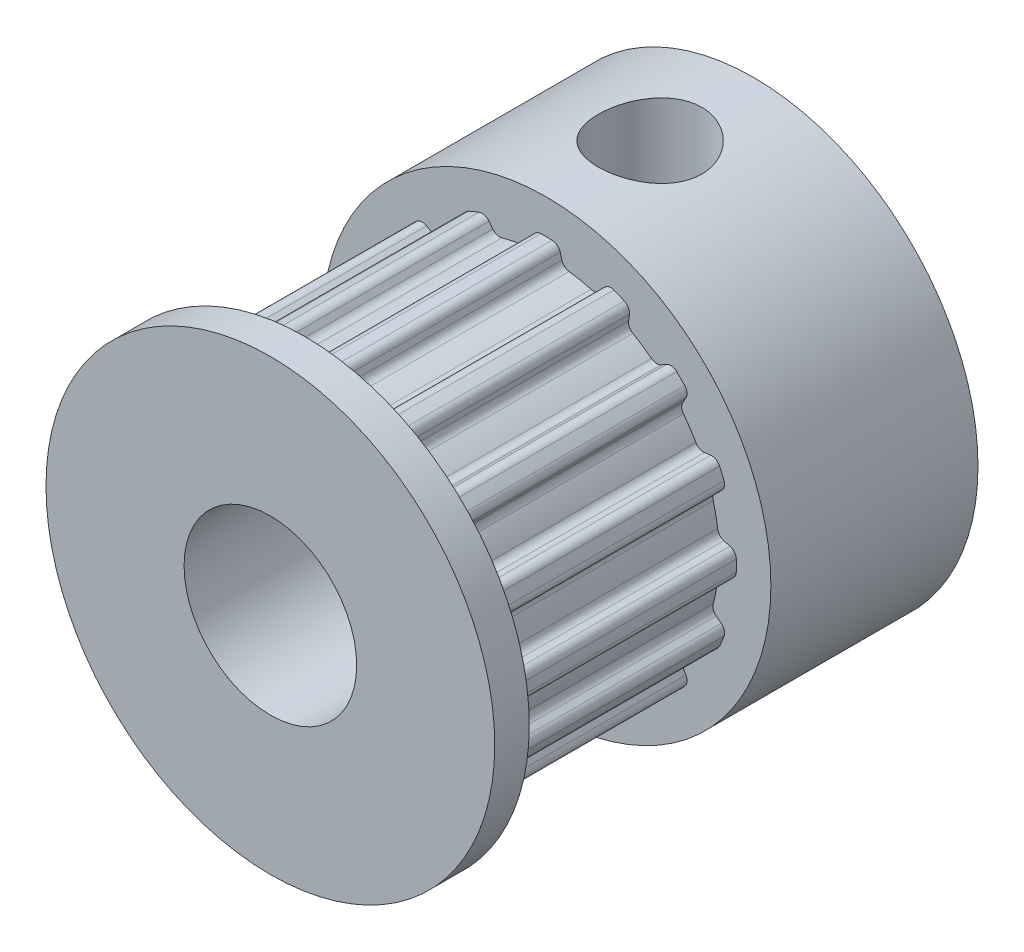
from build123d import *

# Parameters (mm, degrees)
SKETCH1_R           = 6.5
SKETCH1_R_2         = 2.5
BOSS_EXTRUDE1_DEPTH = 6
SKETCH2_R           = 2.5
BOSS_EXTRUDE2_DEPTH = 7
SKETCH3_R           = 6.5
SKETCH3_R_2         = 2.5
BOSS_EXTRUDE3_DEPTH = 1
SKETCH4_R           = 1.5
CUT_EXTRUDE1_DEPTH  = 7.5
SKETCH5_R           = 1.5
CUT_EXTRUDE2_DEPTH  = 7.5000001


with BuildPart() as part:
    # Sketch1 → Boss-Extrude1 (new body)
    with BuildSketch(Plane.XY):
        Circle(SKETCH1_R)
        Circle(SKETCH1_R_2, mode=Mode.SUBTRACT)
    extrude(amount=BOSS_EXTRUDE1_DEPTH)

    # Sketch2 → Boss-Extrude2 (add)
    with BuildSketch(Plane.XY.offset(6)):
        with BuildLine():
            Line((0.445491151, 5.138938457), (0.397701665, 5.313631767))
            ThreePointArc((0.397701665, 5.313631767), (0.311179854, 5.444116778), (0.164017219, 5.497553852))
            ThreePointArc((0.164017219, 5.497553852), (0, 5.5), (-0.164017219, 5.497553852))
            ThreePointArc((-0.164017219, 5.497553852), (-0.311179854, 5.444116778), (-0.397701665, 5.313631767))
            Line((-0.397701665, 5.313631767), (-0.445491151, 5.138938457))
            ThreePointArc((-0.445491151, 5.138938457), (-0.522261752, 5.016536464), (-0.653934215, 4.957052556))
            ThreePointArc((-0.653934215, 4.957052556), (-0.97545161, 4.903926402), (-1.292825449, 4.829969188))
            ThreePointArc((-1.292825449, 4.829969188), (-1.437238449, 4.834536283), (-1.555006451, 4.918242142))
            Line((-1.555006451, 4.918242142), (-1.666010414, 5.061349471))
            ThreePointArc((-1.666010414, 5.061349471), (-1.795880597, 5.148791439), (-1.952290626, 5.141844155))
            ThreePointArc((-1.952290626, 5.141844155), (-2.104758878, 5.081337429), (-2.255354929, 5.01631081))
            ThreePointArc((-2.255354929, 5.01631081), (-2.370865993, 4.91062469), (-2.400867272, 4.756961795))
            Line((-2.400867272, 4.756961795), (-2.378166764, 4.577277976))
            ThreePointArc((-2.378166764, 4.577277976), (-2.402252336, 4.434814443), (-2.501138324, 4.329469608))
            ThreePointArc((-2.501138324, 4.329469608), (-2.777851165, 4.157348062), (-3.042764159, 3.967566795))
            ThreePointArc((-3.042764159, 3.967566795), (-3.177932125, 3.916521778), (-3.318768417, 3.948788045))
            Line((-3.318768417, 3.948788045), (-3.476087511, 4.0385226))
            ThreePointArc((-3.476087511, 4.0385226), (-3.629534507, 4.069609276), (-3.771379921, 4.003335296))
            ThreePointArc((-3.771379921, 4.003335296), (-3.889087297, 3.889087297), (-4.003335296, 3.771379921))
            ThreePointArc((-4.003335296, 3.771379921), (-4.069609276, 3.629534507), (-4.0385226, 3.476087511))
            Line((-4.0385226, 3.476087511), (-3.948788045, 3.318768417))
            ThreePointArc((-3.948788045, 3.318768417), (-3.916521778, 3.177932125), (-3.967566795, 3.042764159))
            ThreePointArc((-3.967566795, 3.042764159), (-4.157348062, 2.777851165), (-4.329469608, 2.501138324))
            ThreePointArc((-4.329469608, 2.501138324), (-4.434814443, 2.402252336), (-4.577277976, 2.378166764))
            Line((-4.577277976, 2.378166764), (-4.756961795, 2.400867272))
            ThreePointArc((-4.756961795, 2.400867272), (-4.91062469, 2.370865993), (-5.01631081, 2.255354929))
            ThreePointArc((-5.01631081, 2.255354929), (-5.081337429, 2.104758878), (-5.141844155, 1.952290626))
            ThreePointArc((-5.141844155, 1.952290626), (-5.148791439, 1.795880597), (-5.061349471, 1.666010414))
            Line((-5.061349471, 1.666010414), (-4.918242142, 1.555006451))
            ThreePointArc((-4.918242142, 1.555006451), (-4.834536283, 1.437238449), (-4.829969188, 1.292825449))
            ThreePointArc((-4.829969188, 1.292825449), (-4.903926402, 0.97545161), (-4.957052556, 0.653934215))
            ThreePointArc((-4.957052556, 0.653934215), (-5.016536464, 0.522261752), (-5.138938457, 0.445491151))
            Line((-5.138938457, 0.445491151), (-5.313631767, 0.397701665))
            ThreePointArc((-5.313631767, 0.397701665), (-5.444116778, 0.311179854), (-5.497553852, 0.164017219))
            ThreePointArc((-5.497553852, 0.164017219), (-5.5, 0), (-5.497553852, -0.164017219))
            ThreePointArc((-5.497553852, -0.164017219), (-5.444116778, -0.311179854), (-5.313631767, -0.397701665))
            Line((-5.313631767, -0.397701665), (-5.138938457, -0.445491151))
            ThreePointArc((-5.138938457, -0.445491151), (-5.016536464, -0.522261752), (-4.957052556, -0.653934215))
            ThreePointArc((-4.957052556, -0.653934215), (-4.903926402, -0.97545161), (-4.829969188, -1.292825449))
            ThreePointArc((-4.829969188, -1.292825449), (-4.834536283, -1.437238449), (-4.918242142, -1.555006451))
            Line((-4.918242142, -1.555006451), (-5.061349471, -1.666010414))
            ThreePointArc((-5.061349471, -1.666010414), (-5.148791439, -1.795880597), (-5.141844155, -1.952290626))
            ThreePointArc((-5.141844155, -1.952290626), (-5.081337429, -2.104758878), (-5.01631081, -2.255354929))
            ThreePointArc((-5.01631081, -2.255354929), (-4.91062469, -2.370865993), (-4.756961795, -2.400867272))
            Line((-4.756961795, -2.400867272), (-4.577277976, -2.378166764))
            ThreePointArc((-4.577277976, -2.378166764), (-4.434814443, -2.402252336), (-4.329469608, -2.501138324))
            ThreePointArc((-4.329469608, -2.501138324), (-4.157348062, -2.777851165), (-3.967566795, -3.042764159))
            ThreePointArc((-3.967566795, -3.042764159), (-3.916521778, -3.177932125), (-3.948788045, -3.318768417))
            Line((-3.948788045, -3.318768417), (-4.0385226, -3.476087511))
            ThreePointArc((-4.0385226, -3.476087511), (-4.069609276, -3.629534507), (-4.003335296, -3.771379921))
            ThreePointArc((-4.003335296, -3.771379921), (-3.889087297, -3.889087297), (-3.771379921, -4.003335296))
            ThreePointArc((-3.771379921, -4.003335296), (-3.629534507, -4.069609276), (-3.476087511, -4.0385226))
            Line((-3.476087511, -4.0385226), (-3.318768417, -3.948788045))
            ThreePointArc((-3.318768417, -3.948788045), (-3.177932125, -3.916521778), (-3.042764159, -3.967566795))
            ThreePointArc((-3.042764159, -3.967566795), (-2.777851165, -4.157348062), (-2.501138324, -4.329469608))
            ThreePointArc((-2.501138324, -4.329469608), (-2.402252336, -4.434814443), (-2.378166764, -4.577277976))
            Line((-2.378166764, -4.577277976), (-2.400867272, -4.756961795))
            ThreePointArc((-2.400867272, -4.756961795), (-2.370865993, -4.91062469), (-2.255354929, -5.01631081))
            ThreePointArc((-2.255354929, -5.01631081), (-2.104758878, -5.081337429), (-1.952290626, -5.141844155))
            ThreePointArc((-1.952290626, -5.141844155), (-1.795880597, -5.148791439), (-1.666010414, -5.061349471))
            Line((-1.666010414, -5.061349471), (-1.555006451, -4.918242142))
            ThreePointArc((-1.555006451, -4.918242142), (-1.437238449, -4.834536283), (-1.292825449, -4.829969188))
            ThreePointArc((-1.292825449, -4.829969188), (-0.97545161, -4.903926402), (-0.653934215, -4.957052556))
            ThreePointArc((-0.653934215, -4.957052556), (-0.522261752, -5.016536464), (-0.445491151, -5.138938457))
            Line((-0.445491151, -5.138938457), (-0.397701665, -5.313631767))
            ThreePointArc((-0.397701665, -5.313631767), (-0.311179854, -5.444116778), (-0.164017219, -5.497553852))
            ThreePointArc((-0.164017219, -5.497553852), (0, -5.5), (0.164017219, -5.497553852))
            ThreePointArc((0.164017219, -5.497553852), (0.311179854, -5.444116778), (0.397701665, -5.313631767))
            Line((0.397701665, -5.313631767), (0.445491151, -5.138938457))
            ThreePointArc((0.445491151, -5.138938457), (0.522261752, -5.016536464), (0.653934215, -4.957052556))
            ThreePointArc((0.653934215, -4.957052556), (0.97545161, -4.903926402), (1.292825449, -4.829969188))
            ThreePointArc((1.292825449, -4.829969188), (1.437238449, -4.834536283), (1.555006451, -4.918242142))
            Line((1.555006451, -4.918242142), (1.666010414, -5.061349471))
            ThreePointArc((1.666010414, -5.061349471), (1.795880597, -5.148791439), (1.952290626, -5.141844155))
            ThreePointArc((1.952290626, -5.141844155), (2.104758878, -5.081337429), (2.255354929, -5.01631081))
            ThreePointArc((2.255354929, -5.01631081), (2.370865993, -4.91062469), (2.400867272, -4.756961795))
            Line((2.400867272, -4.756961795), (2.378166764, -4.577277976))
            ThreePointArc((2.378166764, -4.577277976), (2.402252336, -4.434814443), (2.501138324, -4.329469608))
            ThreePointArc((2.501138324, -4.329469608), (2.777851165, -4.157348062), (3.042764159, -3.967566795))
            ThreePointArc((3.042764159, -3.967566795), (3.177932125, -3.916521778), (3.318768417, -3.948788045))
            Line((3.318768417, -3.948788045), (3.476087511, -4.0385226))
            ThreePointArc((3.476087511, -4.0385226), (3.629534507, -4.069609276), (3.771379921, -4.003335296))
            ThreePointArc((3.771379921, -4.003335296), (3.889087297, -3.889087297), (4.003335296, -3.771379921))
            ThreePointArc((4.003335296, -3.771379921), (4.069609276, -3.629534507), (4.0385226, -3.476087511))
            Line((4.0385226, -3.476087511), (3.948788045, -3.318768417))
            ThreePointArc((3.948788045, -3.318768417), (3.916521778, -3.177932125), (3.967566795, -3.042764159))
            ThreePointArc((3.967566795, -3.042764159), (4.157348062, -2.777851165), (4.329469608, -2.501138324))
            ThreePointArc((4.329469608, -2.501138324), (4.434814443, -2.402252336), (4.577277976, -2.378166764))
            Line((4.577277976, -2.378166764), (4.756961795, -2.400867272))
            ThreePointArc((4.756961795, -2.400867272), (4.91062469, -2.370865993), (5.01631081, -2.255354929))
            ThreePointArc((5.01631081, -2.255354929), (5.081337429, -2.104758878), (5.141844155, -1.952290626))
            ThreePointArc((5.141844155, -1.952290626), (5.148791439, -1.795880597), (5.061349471, -1.666010414))
            Line((5.061349471, -1.666010414), (4.918242142, -1.555006451))
            ThreePointArc((4.918242142, -1.555006451), (4.834536283, -1.437238449), (4.829969188, -1.292825449))
            ThreePointArc((4.829969188, -1.292825449), (4.903926402, -0.97545161), (4.957052556, -0.653934215))
            ThreePointArc((4.957052556, -0.653934215), (5.016536464, -0.522261752), (5.138938457, -0.445491151))
            Line((5.138938457, -0.445491151), (5.313631767, -0.397701665))
            ThreePointArc((5.313631767, -0.397701665), (5.444116778, -0.311179854), (5.497553852, -0.164017219))
            ThreePointArc((5.497553852, -0.164017219), (5.5, 0), (5.497553852, 0.164017219))
            ThreePointArc((5.497553852, 0.164017219), (5.444116778, 0.311179854), (5.313631767, 0.397701665))
            Line((5.313631767, 0.397701665), (5.138938457, 0.445491151))
            ThreePointArc((5.138938457, 0.445491151), (5.016536464, 0.522261752), (4.957052556, 0.653934215))
            ThreePointArc((4.957052556, 0.653934215), (4.903926402, 0.97545161), (4.829969188, 1.292825449))
            ThreePointArc((4.829969188, 1.292825449), (4.834536283, 1.437238449), (4.918242142, 1.555006451))
            Line((4.918242142, 1.555006451), (5.061349471, 1.666010414))
            ThreePointArc((5.061349471, 1.666010414), (5.148791439, 1.795880597), (5.141844155, 1.952290626))
            ThreePointArc((5.141844155, 1.952290626), (5.081337429, 2.104758878), (5.01631081, 2.255354929))
            ThreePointArc((5.01631081, 2.255354929), (4.91062469, 2.370865993), (4.756961795, 2.400867272))
            Line((4.756961795, 2.400867272), (4.577277976, 2.378166764))
            ThreePointArc((4.577277976, 2.378166764), (4.434814443, 2.402252336), (4.329469608, 2.501138324))
            ThreePointArc((4.329469608, 2.501138324), (4.157348062, 2.777851165), (3.967566795, 3.042764159))
            ThreePointArc((3.967566795, 3.042764159), (3.916521778, 3.177932125), (3.948788045, 3.318768417))
            Line((3.948788045, 3.318768417), (4.0385226, 3.476087511))
            ThreePointArc((4.0385226, 3.476087511), (4.069609276, 3.629534507), (4.003335296, 3.771379921))
            ThreePointArc((4.003335296, 3.771379921), (3.889087297, 3.889087297), (3.771379921, 4.003335296))
            ThreePointArc((3.771379921, 4.003335296), (3.629534507, 4.069609276), (3.476087511, 4.0385226))
            Line((3.476087511, 4.0385226), (3.318768417, 3.948788045))
            ThreePointArc((3.318768417, 3.948788045), (3.177932125, 3.916521778), (3.042764159, 3.967566795))
            ThreePointArc((3.042764159, 3.967566795), (2.777851165, 4.157348062), (2.501138324, 4.329469608))
            ThreePointArc((2.501138324, 4.329469608), (2.402252336, 4.434814443), (2.378166764, 4.577277976))
            Line((2.378166764, 4.577277976), (2.400867272, 4.756961795))
            ThreePointArc((2.400867272, 4.756961795), (2.370865993, 4.91062469), (2.255354929, 5.01631081))
            ThreePointArc((2.255354929, 5.01631081), (2.104758878, 5.081337429), (1.952290626, 5.141844155))
            ThreePointArc((1.952290626, 5.141844155), (1.795880597, 5.148791439), (1.666010414, 5.061349471))
            Line((1.666010414, 5.061349471), (1.555006451, 4.918242142))
            ThreePointArc((1.555006451, 4.918242142), (1.437238449, 4.834536283), (1.292825449, 4.829969188))
            ThreePointArc((1.292825449, 4.829969188), (0.97545161, 4.903926402), (0.653934215, 4.957052556))
            ThreePointArc((0.653934215, 4.957052556), (0.522261752, 5.016536464), (0.445491151, 5.138938457))
        make_face()
        Circle(SKETCH2_R, mode=Mode.SUBTRACT)
    extrude(amount=BOSS_EXTRUDE2_DEPTH)

    # Sketch3 → Boss-Extrude3 (add)
    with BuildSketch(Plane.XY.offset(13)):
        Circle(SKETCH3_R)
        Circle(SKETCH3_R_2, mode=Mode.SUBTRACT)
    extrude(amount=BOSS_EXTRUDE3_DEPTH)

    # Sketch4 → Cut-Extrude1 (cut, through all)
    with BuildSketch(Plane(origin=(0, 0, 0), x_dir=(1, 0, 0), z_dir=(0, 1, 0))):
        with Locations((0, -3)):
            Circle(SKETCH4_R)
    extrude(amount=CUT_EXTRUDE1_DEPTH, mode=Mode.SUBTRACT)

    # Sketch5 → Cut-Extrude2 (cut, through all)
    with BuildSketch(Plane(origin=(0, 0, 0), x_dir=(0, 0, -1), z_dir=(1, 0, 0))):
        with Locations((-3, 0)):
            Circle(SKETCH5_R)
    extrude(amount=-CUT_EXTRUDE2_DEPTH, mode=Mode.SUBTRACT)


solid = part.part
